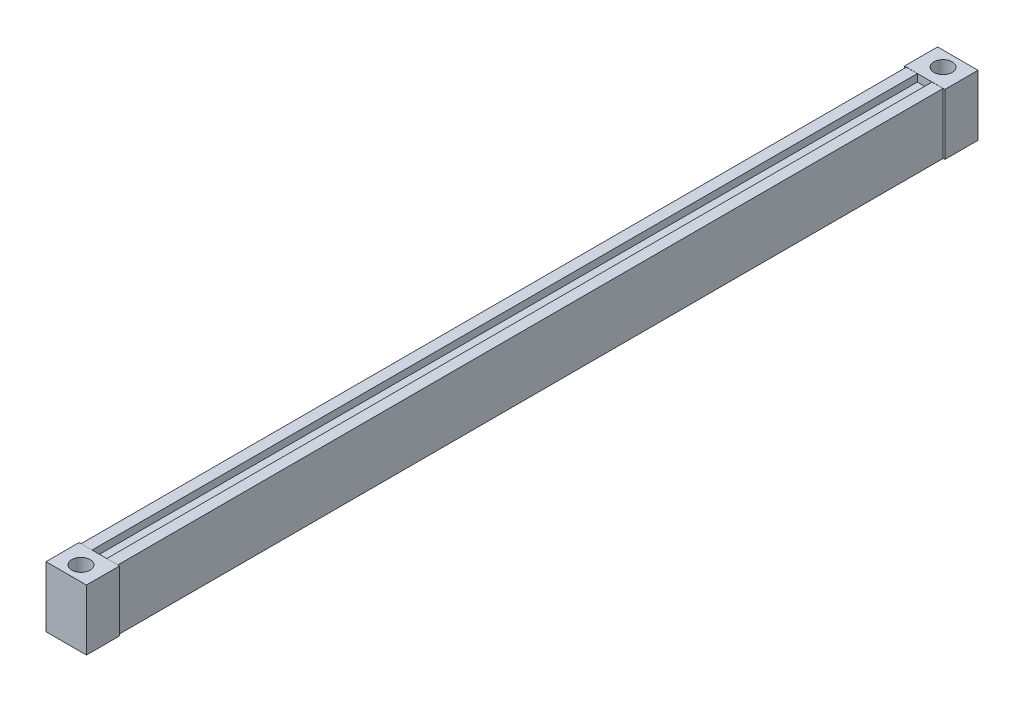
from build123d import *

# Parameters (mm, degrees)
BOSS_EXTRUDE1_DEPTH      = 224.5
BOSS_EXTRUDE1_DEPTH_BACK = 224.5
SKETCH1_W                = 20
SKETCH1_H                = 33
SKETCH18_W               = 8
SKETCH18_H               = 449
CUT_EXTRUDE6_DEPTH       = 4
SKETCH19_W               = 22
SKETCH19_H               = 33
BOSS_EXTRUDE5_DEPTH      = 18
SKETCH20_R               = 2.5
CUT_EXTRUDE7_DEPTH       = 246.233707055
SKETCH20_4_R             = 5
SKETCH20_4_R_2           = 2.5
CUT_EXTRUDE8_DEPTH       = 28


with BuildPart() as part:
    # Sketch1 → Boss-Extrude1 (new, two sides: drawn at the far end of the back side and taken through both)
    with BuildSketch(Plane.XY.offset(-BOSS_EXTRUDE1_DEPTH_BACK)):
        with Locations((-4.5, 8.759259259)):
            Rectangle(SKETCH1_W, SKETCH1_H)
    extrude(amount=BOSS_EXTRUDE1_DEPTH + BOSS_EXTRUDE1_DEPTH_BACK)

    # Sketch18 → Cut-Extrude6 (cut)
    with BuildSketch(Plane(origin=(0, 25.259259259, 0), x_dir=(1, 0, 0), z_dir=(0, 1, 0))):
        with Locations((-4.5, 0)):
            Rectangle(SKETCH18_W, SKETCH18_H)
    extrude(amount=-CUT_EXTRUDE6_DEPTH, mode=Mode.SUBTRACT)


with BuildPart() as body_2:
    # Sketch19 → Boss-Extrude5 (new body)
    with BuildSketch(Plane(origin=(0, 0, -224.5), x_dir=(-1, 0, 0), z_dir=(0, 0, -1))):
        with Locations((4.5, 8.82088469)):
            Rectangle(SKETCH19_W, SKETCH19_H)
    extrude(amount=BOSS_EXTRUDE5_DEPTH)

    # Sketch20 → Cut-Extrude7 (cut, through all)
    with BuildSketch(Plane(origin=(0, 25.32088469, 0), x_dir=(1, 0, 0), z_dir=(0, 1, 0))):
        with Locations((-4.5, 234.5)):
            Circle(SKETCH20_R)
    extrude(amount=-CUT_EXTRUDE7_DEPTH, mode=Mode.SUBTRACT)

    # Sketch20_4 → Cut-Extrude8 (cut)
    with BuildSketch(Plane(origin=(0, 25.32088469, 0), x_dir=(1, 0, 0), z_dir=(0, 1, 0))):
        with Locations((-4.5, 234.5)):
            Circle(SKETCH20_4_R)
        with Locations((-4.5, 234.5)):
            Circle(SKETCH20_4_R_2, mode=Mode.SUBTRACT)
    extrude(amount=-CUT_EXTRUDE8_DEPTH, mode=Mode.SUBTRACT)


with BuildPart() as body_3:
    # Mirror8: mirrored copy
    add(body_2.part.mirror(Plane(origin=(0, 0, 0), x_dir=(1, 0, 0), z_dir=(0, 0, -1))))


solid = Compound([part.part, body_2.part, body_3.part])
